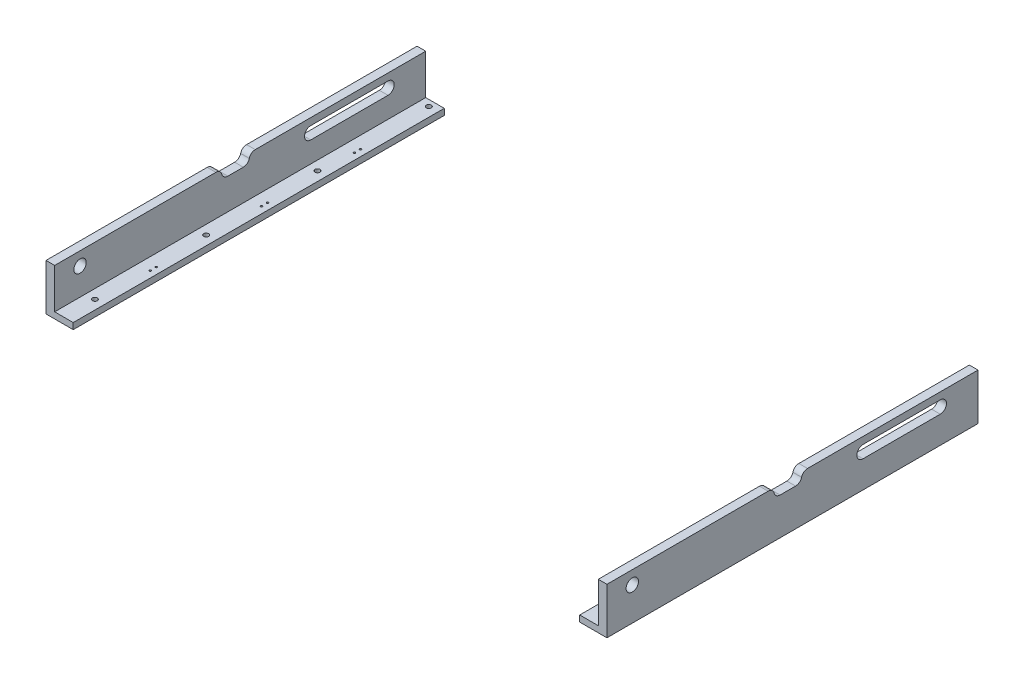
from build123d import *

# Parameters (mm, degrees)
SKETCH1_W                = 30
SKETCH1_H                = 600
BOSS_EXTRUDE1_DEPTH      = 10
BOSS_EXTRUDE1_2_DEPTH    = 10
SKETCH_2_W               = 600
SKETCH_2_H               = 75
SKETCH_2_R               = 10
EXTRUDE_1_DEPTH          = 14
SKETCH_3_W               = 600
SKETCH_3_H               = 75
SKETCH_3_R               = 10
EXTRUDE_2_DEPTH          = 14
CUT_EXTRUDE_4_DEPTH      = 57
CUT_EXTRUDE_4_DEPTH_BACK = 1083
SKETCH_8_R               = 4
CUT_EXTRUDE_5_DEPTH      = 96
CUT_EXTRUDE_6_DEPTH      = 1028
FILLET_1_R               = 10
FILLET_2_R               = 10
SKETCH_11_R              = 1.5
CUT_EXTRUDE_7_DEPTH      = 10


with BuildPart() as part:
    # Sketch1 → Boss-Extrude1 (new body)
    with BuildSketch(Plane(origin=(0, 0, 0), x_dir=(1, 0, 0), z_dir=(0, 1, 0))):
        with Locations((-424.5, 0)):
            Rectangle(SKETCH1_W, SKETCH1_H)
    extrude(amount=BOSS_EXTRUDE1_DEPTH)

    # 草图2 → 凸台-拉伸1 (add)
    with BuildSketch(Plane.ZY.offset(439.5)):
        with Locations((0, 37.5)):
            Rectangle(SKETCH_2_W, SKETCH_2_H)
        with Locations((258.993384408, 53.607709477)):
            Circle(SKETCH_2_R, mode=Mode.SUBTRACT)
    extrude(amount=EXTRUDE_1_DEPTH)


with BuildPart() as body_2:
    # Sketch1 → Boss-Extrude1 2 (new body)
    with BuildSketch(Plane(origin=(0, 0, 0), x_dir=(1, 0, 0), z_dir=(0, 1, 0))):
        with Locations((424.5, 0)):
            Rectangle(SKETCH1_W, SKETCH1_H)
    extrude(amount=BOSS_EXTRUDE1_2_DEPTH)

    # 草图3 → 凸台-拉伸2 (add)
    with BuildSketch(Plane(origin=(439.5, 0, 0), x_dir=(0, 0, -1), z_dir=(1, 0, 0))):
        with Locations((0, 37.5)):
            Rectangle(SKETCH_3_W, SKETCH_3_H)
        with Locations((-258.993384408, 53.607709477)):
            Circle(SKETCH_3_R, mode=Mode.SUBTRACT)
    extrude(amount=EXTRUDE_2_DEPTH)


with BuildPart() as cut_extrude_4_tool:
    # 草图5 → 切除-拉伸4 (new body, two sides)
    with BuildSketch(Plane(origin=(439.5, 0, 0), x_dir=(0, 0, -1), z_dir=(1, 0, 0))) as cut_extrude_4_sk:
        with BuildLine():
            Line((114.006603289, 63.704150634), (239.006603289, 63.704150634))
            ThreePointArc((239.006603289, 63.704150634), (249.006603289, 53.704150634), (239.006603289, 43.704150634))
            Line((239.006603289, 43.704150634), (114.006603289, 43.704150634))
            ThreePointArc((114.006603289, 43.704150634), (104.006603289, 53.704150634), (114.006603289, 63.704150634))
        make_face()
    extrude(amount=CUT_EXTRUDE_4_DEPTH)
    extrude(cut_extrude_4_sk.sketch, amount=-CUT_EXTRUDE_4_DEPTH_BACK)


with BuildPart() as part_1:
    add(part.part)

    # 切除-拉伸4: cut by cut_extrude_4_tool
    add(cut_extrude_4_tool.part, mode=Mode.SUBTRACT)


with BuildPart() as body_2_1:
    add(body_2.part)

    # 切除-拉伸4: cut by cut_extrude_4_tool
    add(cut_extrude_4_tool.part, mode=Mode.SUBTRACT)


with BuildPart() as cut_extrude_5_tool:
    # 草图8 → 切除-拉伸5 (new body)
    with BuildSketch(Plane(origin=(0, 10, 0), x_dir=(1, 0, 0), z_dir=(0, 1, 0))):
        with Locations((424.5, -69.99339056)):
            Circle(SKETCH_8_R)
        with Locations((424.5, 110.00660944)):
            Circle(SKETCH_8_R)
        with Locations((424.5, 290.00660944)):
            Circle(SKETCH_8_R)
        with Locations((424.5, -249.99339056)):
            Circle(SKETCH_8_R)
        with Locations((-424.5, -249.99339056)):
            Circle(SKETCH_8_R)
        with Locations((-424.5, 290.00660944)):
            Circle(SKETCH_8_R)
        with Locations((-424.5, 110.00660944)):
            Circle(SKETCH_8_R)
        with Locations((-424.5, -69.99339056)):
            Circle(SKETCH_8_R)
    extrude(amount=-CUT_EXTRUDE_5_DEPTH)


with BuildPart() as part_2:
    add(part_1.part)

    # 切除-拉伸5: cut by cut_extrude_5_tool
    add(cut_extrude_5_tool.part, mode=Mode.SUBTRACT)


with BuildPart() as body_2_2:
    add(body_2_1.part)

    # 切除-拉伸5: cut by cut_extrude_5_tool
    add(cut_extrude_5_tool.part, mode=Mode.SUBTRACT)


with BuildPart() as cut_extrude_6_tool:
    # 草图9 → 切除-拉伸6 (new body)
    with BuildSketch(Plane.ZY.offset(453.5)):
        with BuildLine():
            Line((0, 60), (20, 60))
            ThreePointArc((20, 60), (27.071067812, 62.928932188), (30, 70))
            Line((30, 70), (30, 75))
            Line((30, 75), (0, 75))
            Line((0, 75), (-15, 75))
            Line((-15, 75), (-15, 70))
            ThreePointArc((-15, 70), (-12.071067812, 62.928932188), (-5, 60))
            Line((-5, 60), (0, 60))
        make_face()
    extrude(amount=-CUT_EXTRUDE_6_DEPTH)


with BuildPart() as part_3:
    add(part_2.part)

    # 切除-拉伸6: cut by cut_extrude_6_tool
    add(cut_extrude_6_tool.part, mode=Mode.SUBTRACT)

    # 圆角1
    fillet_1_edges = [part_3.edges().sort_by_distance(p)[0] for p in [
        (-446.5, 75, 30),
        (-446.5, 75, -15),
    ]]
    fillet(fillet_1_edges, radius=FILLET_1_R)


with BuildPart() as body_2_3:
    add(body_2_2.part)

    # 切除-拉伸6: cut by cut_extrude_6_tool
    add(cut_extrude_6_tool.part, mode=Mode.SUBTRACT)

    # 圆角2
    fillet_2_edges = [body_2_3.edges().sort_by_distance(p)[0] for p in [
        (446.5, 75, 30),
        (446.5, 75, -15),
    ]]
    fillet(fillet_2_edges, radius=FILLET_2_R)


with BuildPart() as cut_extrude_7_tool:
    # 草图11 → 切除-拉伸7 (new body)
    with BuildSketch(Plane(origin=(0, 10, 0), x_dir=(1, 0, 0), z_dir=(0, 1, 0))):
        with Locations((-420, -154.99339056)):
            Circle(SKETCH_11_R)
        with Locations((-420, -164.99339056)):
            Circle(SKETCH_11_R)
        with Locations((-420, 25.00660944)):
            Circle(SKETCH_11_R)
        with Locations((-420, 15.00660944)):
            Circle(SKETCH_11_R)
        with Locations((420, 165.00660944)):
            Circle(SKETCH_11_R)
        with Locations((-420, 175.00660944)):
            Circle(SKETCH_11_R)
        with Locations((420, 175.00660944)):
            Circle(SKETCH_11_R)
        with Locations((-420, 165.00660944)):
            Circle(SKETCH_11_R)
        with Locations((420, 15.00660944)):
            Circle(SKETCH_11_R)
        with Locations((420, 25.00660944)):
            Circle(SKETCH_11_R)
        with Locations((420, -164.99339056)):
            Circle(SKETCH_11_R)
        with Locations((420, -154.99339056)):
            Circle(SKETCH_11_R)
    extrude(amount=-CUT_EXTRUDE_7_DEPTH)


with BuildPart() as part_4:
    add(part_3.part)

    # 切除-拉伸7: cut by cut_extrude_7_tool
    add(cut_extrude_7_tool.part, mode=Mode.SUBTRACT)


with BuildPart() as body_2_4:
    add(body_2_3.part)

    # 切除-拉伸7: cut by cut_extrude_7_tool
    add(cut_extrude_7_tool.part, mode=Mode.SUBTRACT)


solid = Compound([part_4.part, body_2_4.part])
